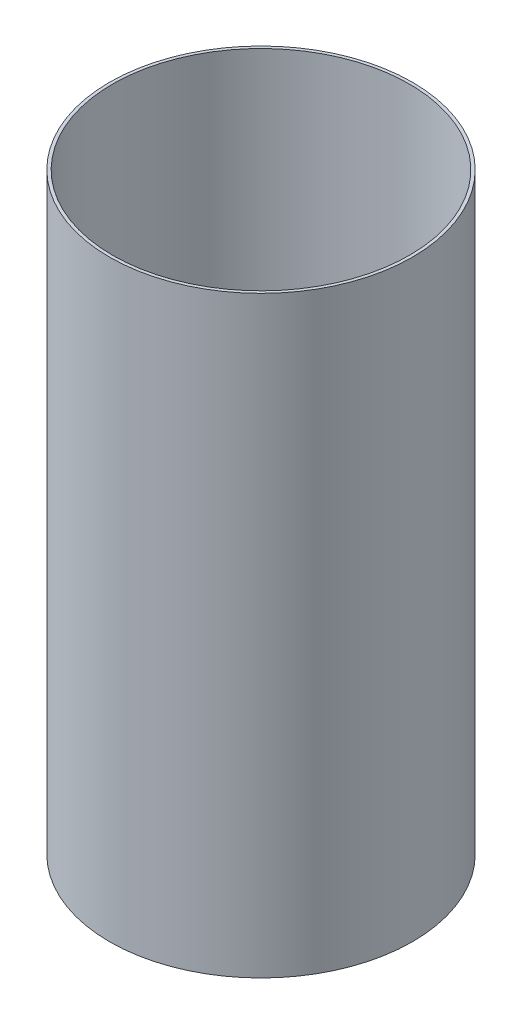
from build123d import *

# Parameters (mm, degrees)
SKETCH1_R           = 77.8637
SKETCH1_R_2         = 76.2889
BOSS_EXTRUDE1_DEPTH = 304.8


with BuildPart() as part:
    # Sketch1 → Boss-Extrude1 (new body)
    with BuildSketch(Plane(origin=(0, 0, 0), x_dir=(1, 0, 0), z_dir=(0, 1, 0))):
        Circle(SKETCH1_R)
        Circle(SKETCH1_R_2, mode=Mode.SUBTRACT)
    extrude(amount=BOSS_EXTRUDE1_DEPTH)


solid = part.part
